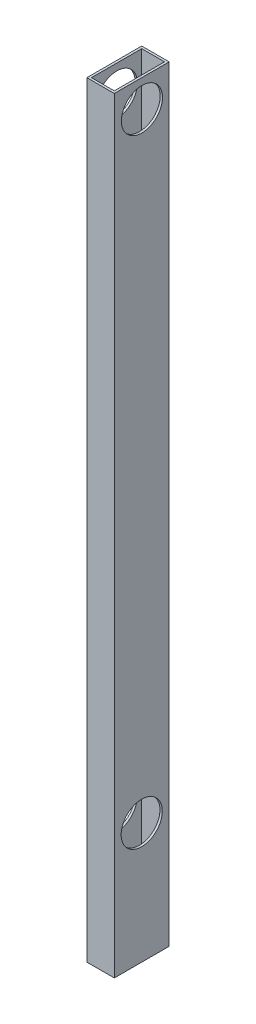
from build123d import *

# Parameters (mm, degrees)
SKETCH1_W           = 19.05
SKETCH1_H           = 38.1
SKETCH1_W_2         = 15.875
SKETCH1_H_2         = 34.925
EXTRUDE_THIN1_DEPTH = 457.2
SKETCH3_W           = 19.05
SKETCH3_H           = 38.1
SKETCH3_W_2         = 15.875
SKETCH3_H_2         = 34.925
EXTRUDE_THIN2_DEPTH = 75.184
SKETCH4_R           = 14.2875
CUT_EXTRUDE1_DEPTH  = 20.05


with BuildPart() as part:
    # Sketch1 → Extrude-Thin1 (new body)
    with BuildSketch(Plane(origin=(0, 0, 0), x_dir=(1, 0, 0), z_dir=(0, 1, 0))):
        with Locations((9.525, 19.05)):
            Rectangle(SKETCH1_W, SKETCH1_H)
        with Locations((9.525, 19.05)):
            Rectangle(SKETCH1_W_2, SKETCH1_H_2, mode=Mode.SUBTRACT)
    extrude(amount=EXTRUDE_THIN1_DEPTH)

    # Sketch3 → Extrude-Thin2 (add)
    with BuildSketch(Plane(origin=(0, 0, 0), x_dir=(-1, 0, 0), z_dir=(0, -1, 0))):
        with Locations((-9.525, 19.05)):
            Rectangle(SKETCH3_W, SKETCH3_H)
        with Locations((-9.525, 19.05)):
            Rectangle(SKETCH3_W_2, SKETCH3_H_2, mode=Mode.SUBTRACT)
    extrude(amount=EXTRUDE_THIN2_DEPTH)

    # Sketch4 → Cut-Extrude1 (cut, through all)
    with BuildSketch(Plane(origin=(19.05, 0, 0), x_dir=(0, 0, -1), z_dir=(1, 0, 0))):
        with Locations((19.2024, 438.15)):
            Circle(SKETCH4_R)
        with Locations((19.05, 8.636)):
            Circle(SKETCH4_R)
    extrude(amount=-CUT_EXTRUDE1_DEPTH, mode=Mode.SUBTRACT)


solid = part.part
